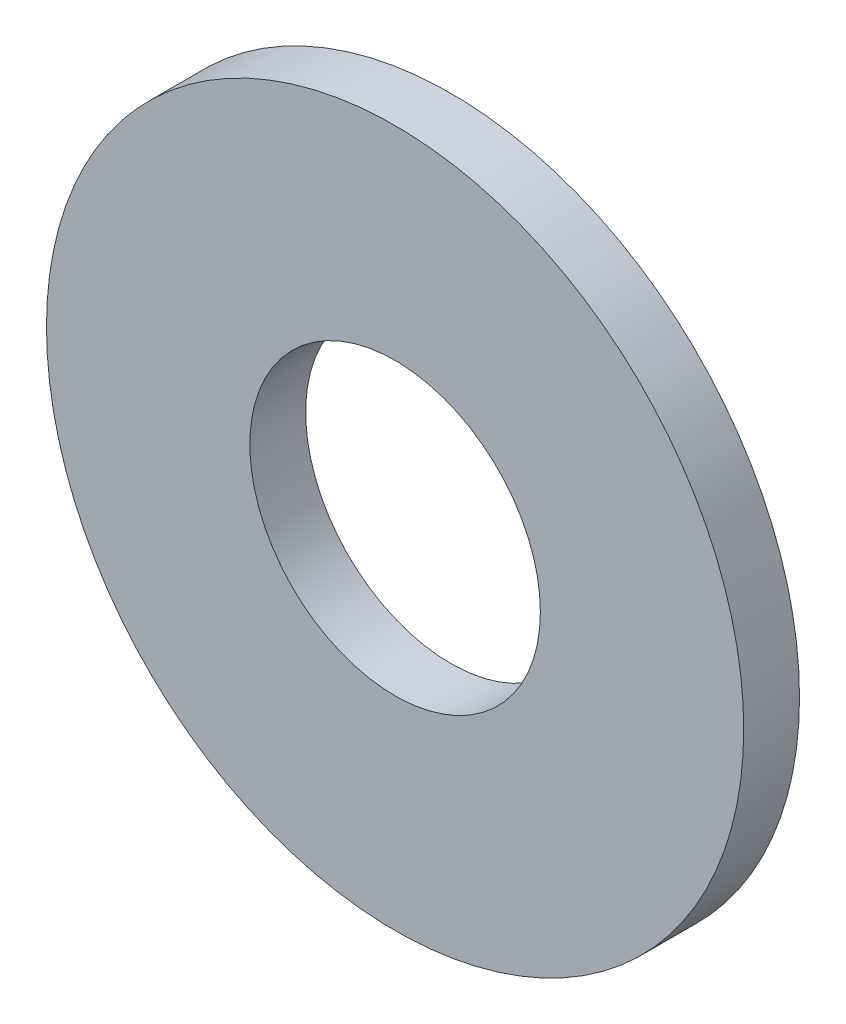
from build123d import *

# Parameters (mm, degrees)
SKETCH1_R      = 4.7625
SKETCH1_R_2    = 1.984375
EXTRUDE1_DEPTH = 0.762


with BuildPart() as part:
    # Sketch1 → Extrude1 (new body)
    with BuildSketch(Plane.XY):
        Circle(SKETCH1_R)
        Circle(SKETCH1_R_2, mode=Mode.SUBTRACT)
    extrude(amount=-EXTRUDE1_DEPTH)


solid = part.part
